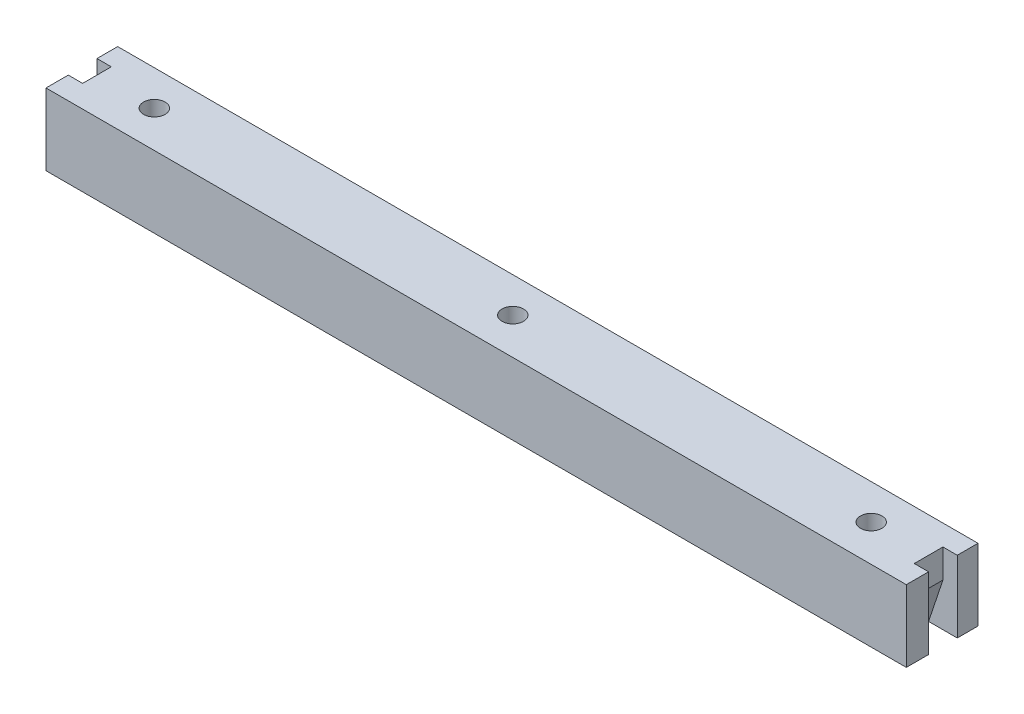
from build123d import *

# Parameters (mm, degrees)
ESQUISSE1_W                  = 120
ESQUISSE1_H                  = 10
ESQUISSE1_R                  = 1.5
BOSS_EXTRU_1_DEPTH           = 10
ENL_V_MAT_EXTRU_1_DEPTH      = 2
ENL_V_MAT_EXTRU_1_DEPTH_BACK = 2


with BuildPart() as part:
    # Esquisse1 → Boss.-Extru.1 (new body)
    with BuildSketch(Plane(origin=(0, 0, 0), x_dir=(1, 0, 0), z_dir=(0, 1, 0))):
        with Locations((0, -0.107913669)):
            Rectangle(ESQUISSE1_W, ESQUISSE1_H)
        with Locations((-50, 0)):
            Circle(ESQUISSE1_R, mode=Mode.SUBTRACT)
        Circle(ESQUISSE1_R, mode=Mode.SUBTRACT)
        with Locations((50, 0)):
            Circle(ESQUISSE1_R, mode=Mode.SUBTRACT)
    extrude(amount=BOSS_EXTRU_1_DEPTH)

    # Esquisse2 → Enlèv. mat.-Extru.1 (cut, two sides)
    with BuildSketch(Plane.XY) as enl_v_mat_extru_1_sk:
        Polygon((-58, 10), (-58, 6), (-56, 0), (-56, -10.800752999), (-73.153181154, -10.800752999), (-73.153181154, 18.339979991), (-58, 18.339979991), align=None)
        Polygon((58, 10), (58, 6), (56, 0), (56, -10.800752999), (73.153181154, -10.800752999), (73.153181154, 18.339979991), (58, 18.339979991), align=None)
    extrude(amount=ENL_V_MAT_EXTRU_1_DEPTH, mode=Mode.SUBTRACT)
    extrude(enl_v_mat_extru_1_sk.sketch, amount=-ENL_V_MAT_EXTRU_1_DEPTH_BACK, mode=Mode.SUBTRACT)


solid = part.part
